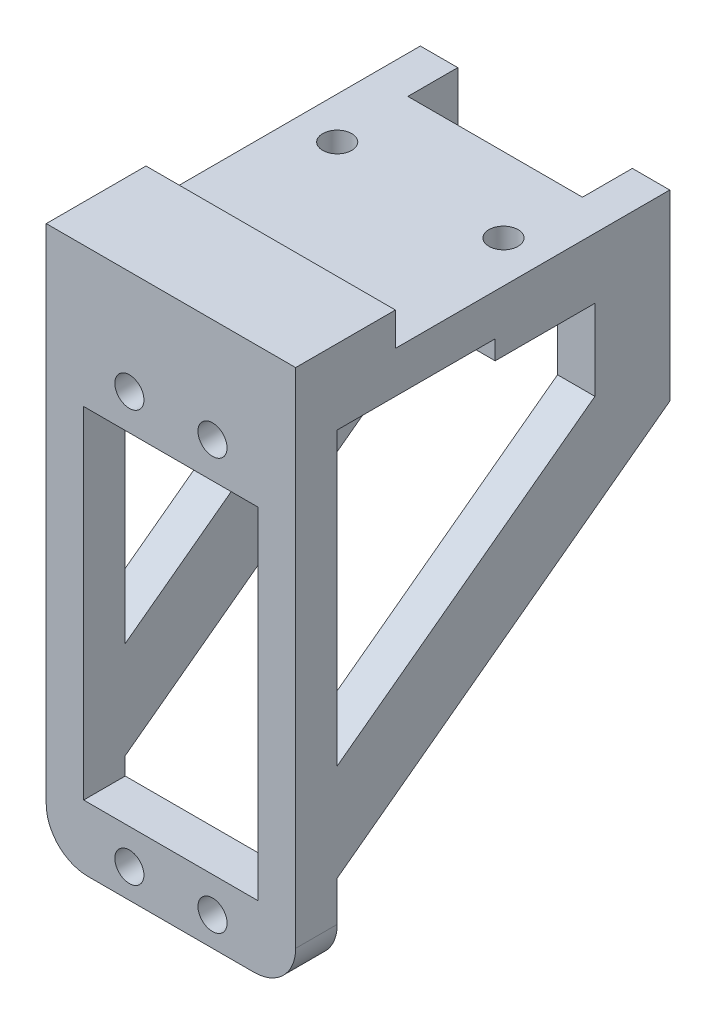
from build123d import *

# Parameters (mm, degrees)
SKETCH_1_W          = 30
SKETCH_1_H          = 61.5
EXTRUDE_1_DEPTH     = 5
SKETCH_2_R          = 1.75
SKETCH_2_W          = 21
SKETCH_2_H          = 41
CUT_EXTRUDE_1_DEPTH = 6
SKETCH_3_W          = 30
SKETCH_3_H          = 40
EXTRUDE_2_DEPTH     = 5
SKETCH_4_R          = 1.75
CUT_EXTRUDE_2_DEPTH = 62.5
SKETCH_5_W          = 10
SKETCH_5_H          = 12
EXTRUDE_3_DEPTH     = 2.3
SKETCH_6_W          = 30
SKETCH_6_H          = 12
EXTRUDE_4_DEPTH     = 4
EXTRUDE_5_DEPTH     = 4.5
FILLET_1_R          = 5
SKETCH_8_W          = 21
SKETCH_8_H          = 6
CUT_EXTRUDE_3_DEPTH = 10


with BuildPart() as part:
    # ｽｹｯﾁ1 → ﾎﾞｽ - 押し出し1 (new body)
    with BuildSketch(Plane.XY):
        with Locations((15, 30.75)):
            Rectangle(SKETCH_1_W, SKETCH_1_H)
    extrude(amount=EXTRUDE_1_DEPTH)

    # ｽｹｯﾁ2 → ｶｯﾄ - 押し出し1 (cut, through all)
    with BuildSketch(Plane.XY.offset(5)):
        with Locations((10, 3.5)):
            Circle(SKETCH_2_R)
        with Locations((20, 3.5)):
            Circle(SKETCH_2_R)
        with Locations((10, 53)):
            Circle(SKETCH_2_R)
        with Locations((20, 53)):
            Circle(SKETCH_2_R)
        with Locations((15, 28.2)):
            Rectangle(SKETCH_2_W, SKETCH_2_H)
    extrude(amount=-CUT_EXTRUDE_1_DEPTH, mode=Mode.SUBTRACT)

    # ｽｹｯﾁ3 → ﾎﾞｽ - 押し出し2 (add)
    with BuildSketch(Plane(origin=(0, 61.5, 0), x_dir=(1, 0, 0), z_dir=(0, 1, 0))):
        with Locations((15, 20)):
            Rectangle(SKETCH_3_W, SKETCH_3_H)
    extrude(amount=-EXTRUDE_2_DEPTH)

    # ｽｹｯﾁ4 → ｶｯﾄ - 押し出し2 (cut, through all)
    with BuildSketch(Plane(origin=(0, 61.5, 0), x_dir=(1, 0, 0), z_dir=(0, 1, 0))):
        with Locations((5, 25)):
            Circle(SKETCH_4_R)
        with Locations((25, 25)):
            Circle(SKETCH_4_R)
    extrude(amount=-CUT_EXTRUDE_2_DEPTH, mode=Mode.SUBTRACT)

    # ｽｹｯﾁ5 → ﾎﾞｽ - 押し出し3 (add)
    with BuildSketch(Plane.XZ.offset(-56.5)):
        with Locations((5, -25)):
            Rectangle(SKETCH_5_W, SKETCH_5_H)
        Polygon((5, -28.6), (8.117691454, -26.8), (8.117691454, -23.2), (5, -21.4), (1.882308546, -23.2), (1.882308546, -26.8), align=None, mode=Mode.SUBTRACT)
        with Locations((25, -25)):
            Rectangle(SKETCH_5_W, SKETCH_5_H)
        Polygon((28.117691454, -26.8), (25, -28.6), (21.882308546, -26.8), (21.882308546, -23.2), (25, -21.4), (28.117691454, -23.2), align=None, mode=Mode.SUBTRACT)
    extrude(amount=EXTRUDE_3_DEPTH)

    # ｽｹｯﾁ6 → ﾎﾞｽ - 押し出し4 (add)
    with BuildSketch(Plane(origin=(0, 61.5, 0), x_dir=(1, 0, 0), z_dir=(0, 1, 0))):
        with Locations((15, 1)):
            Rectangle(SKETCH_6_W, SKETCH_6_H)
    extrude(amount=EXTRUDE_4_DEPTH)

    # ｽｹｯﾁ7 → ﾎﾞｽ - 押し出し5 (add)
    with BuildSketch(Plane(origin=(30, 0, 0), x_dir=(0, 0, -1), z_dir=(1, 0, 0))):
        Polygon((40, 56.5), (40, 39.5), (0, 9.822580645), (0, 21.5), (31, 44.5), (31, 56.5), align=None)
    extrude_5 = extrude(amount=-EXTRUDE_5_DEPTH)

    # ﾐﾗｰ1: ﾎﾞｽ - 押し出し5 across plane
    add(extrude_5.mirror(Plane.ZY.offset(-15)))

    # ﾌｨﾚｯﾄ1
    fillet_1_edges = [part.edges().sort_by_distance(p)[0] for p in [
        (30, 0, 2.5),
        (0, 0, 2.5),
    ]]
    fillet(fillet_1_edges, radius=FILLET_1_R)

    # ｽｹｯﾁ8 → ｶｯﾄ - 押し出し3 (cut, through all)
    with BuildSketch(Plane.XZ.offset(-56.5)):
        with Locations((15, -37)):
            Rectangle(SKETCH_8_W, SKETCH_8_H)
    extrude(amount=-CUT_EXTRUDE_3_DEPTH, mode=Mode.SUBTRACT)


solid = part.part
